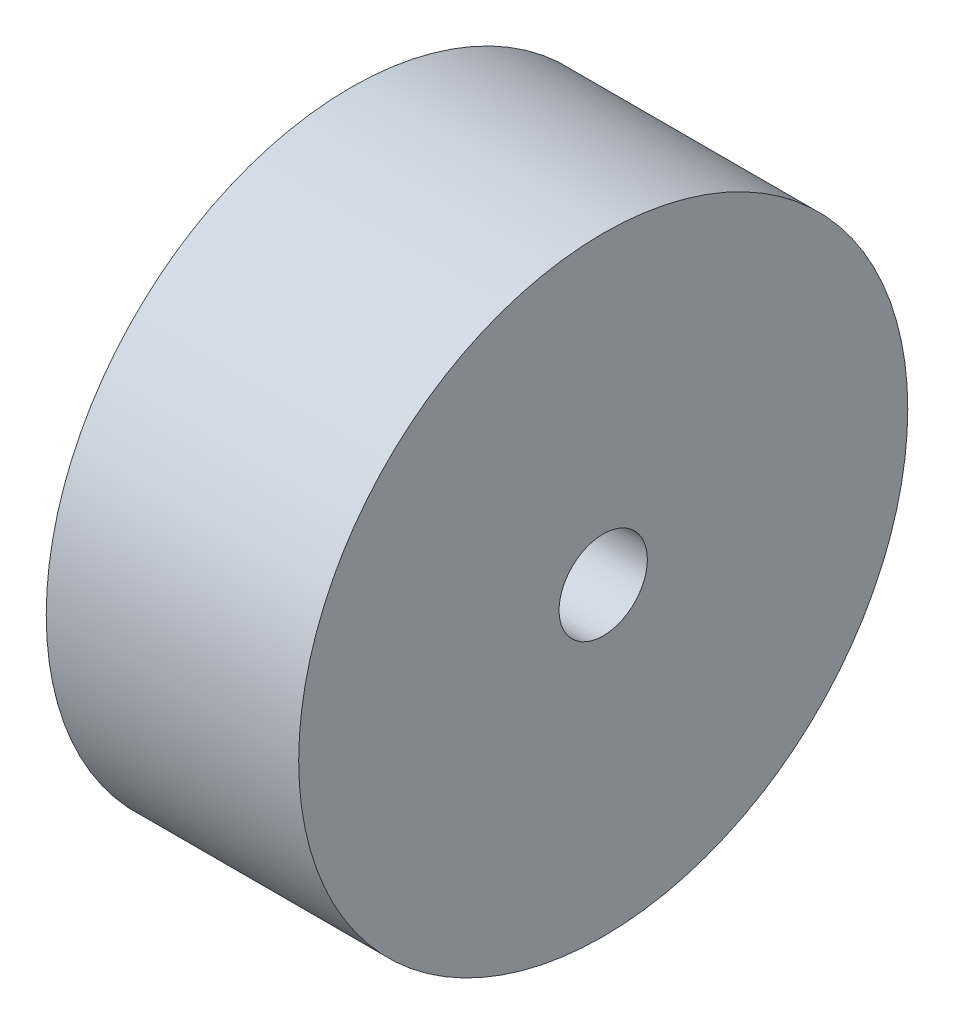
from build123d import *

# Parameters (mm, degrees)
SKETCH1_R               = 17.25
BOSS_EXTRUDE1_DEPTH     = 14.3
SKETCH2_R               = 2.5
CUT_EXTRUDE1_DEPTH      = 1
CUT_EXTRUDE1_DEPTH_BACK = 15.3


with BuildPart() as part:
    # Sketch1 → Boss-Extrude1 (new body)
    with BuildSketch(Plane(origin=(0, 0, 0), x_dir=(0, 0, -1), z_dir=(1, 0, 0))):
        Circle(SKETCH1_R)
    extrude(amount=BOSS_EXTRUDE1_DEPTH)

    # Sketch2 → Cut-Extrude1 (cut, two sides)
    with BuildSketch(Plane(origin=(14.3, 0, 0), x_dir=(0, 0, -1), z_dir=(1, 0, 0))) as cut_extrude1_sk:
        Circle(SKETCH2_R)
    extrude(amount=CUT_EXTRUDE1_DEPTH, mode=Mode.SUBTRACT)
    extrude(cut_extrude1_sk.sketch, amount=-CUT_EXTRUDE1_DEPTH_BACK, mode=Mode.SUBTRACT)


solid = part.part
